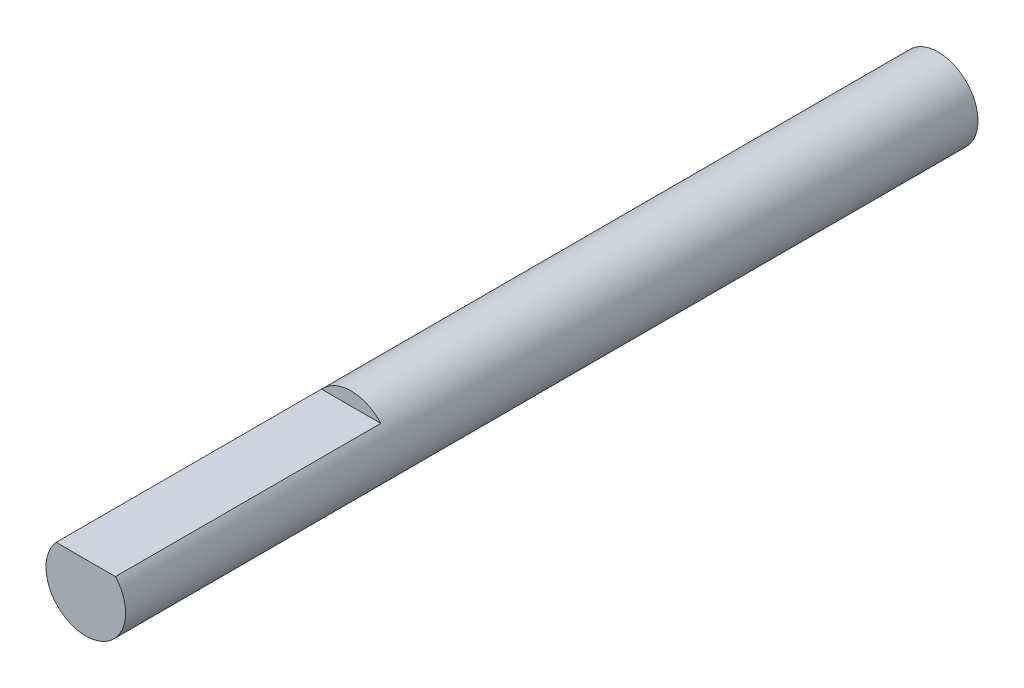
from build123d import *

# Parameters (mm, degrees)
SKETCH1_R           = 1.5
BOSS_EXTRUDE1_DEPTH = 16.0625
CUT_EXTRUDE1_DEPTH  = 10


with BuildPart() as part:
    # Sketch1 → Boss-Extrude1 (new body, symmetric)
    with BuildSketch(Plane.XY):
        Circle(SKETCH1_R)
    extrude(amount=BOSS_EXTRUDE1_DEPTH, both=True)

    # Sketch2 → Cut-Extrude1 (cut)
    with BuildSketch(Plane.XY.offset(16.0625)):
        with BuildLine():
            Line((1.118033989, 1), (-1.118033989, 1))
            ThreePointArc((-1.118033989, 1), (0, 1.5), (1.118033989, 1))
        make_face()
    extrude(amount=-CUT_EXTRUDE1_DEPTH, mode=Mode.SUBTRACT)


solid = part.part
